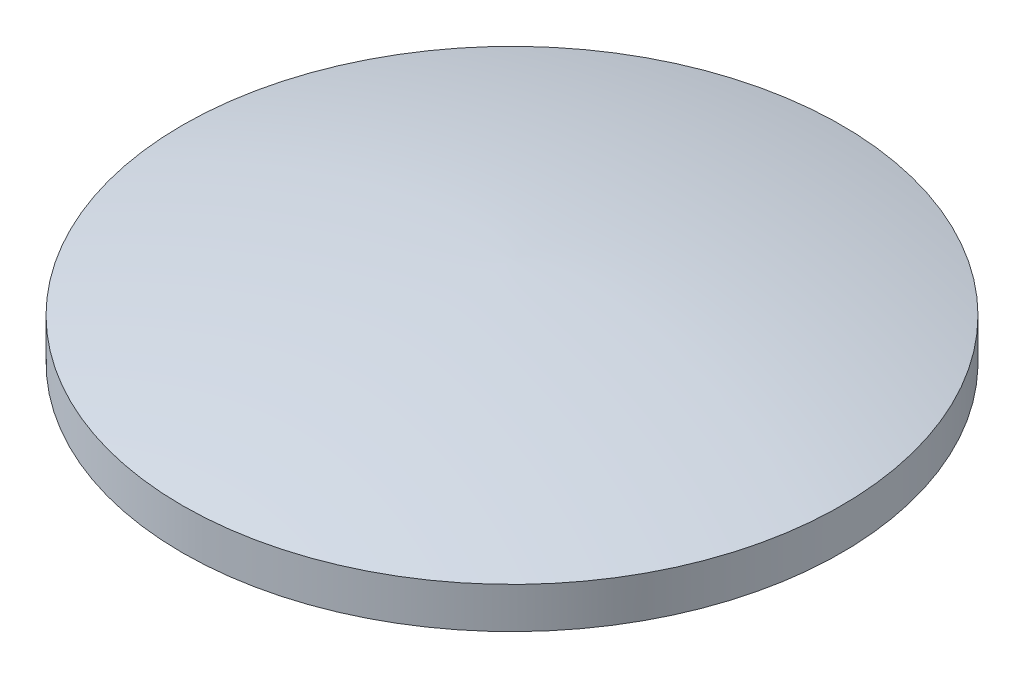
from build123d import *


with BuildPart() as part:
    # Sketch1 → Revolve1 (revolve)
    with BuildSketch(Plane.XY):
        with BuildLine():
            Line((0, 4.807038322), (0, 5.807038322))
            add(Edge.make_bspline(
                [(0, 5.807038322), (3.932019928, 6.896929891), (8.055, 6.988683552)],
                knots=[0, 0, 0, 1, 1, 1], degree=2))
            Line((8.055, 6.988683552), (8.055, 4.807038322))
            Line((8.055, 4.807038322), (0, 4.807038322))
        make_face()
    revolve(axis=Axis((8.055, 6.988683552, 0), (0, -1, 0)))


solid = part.part
